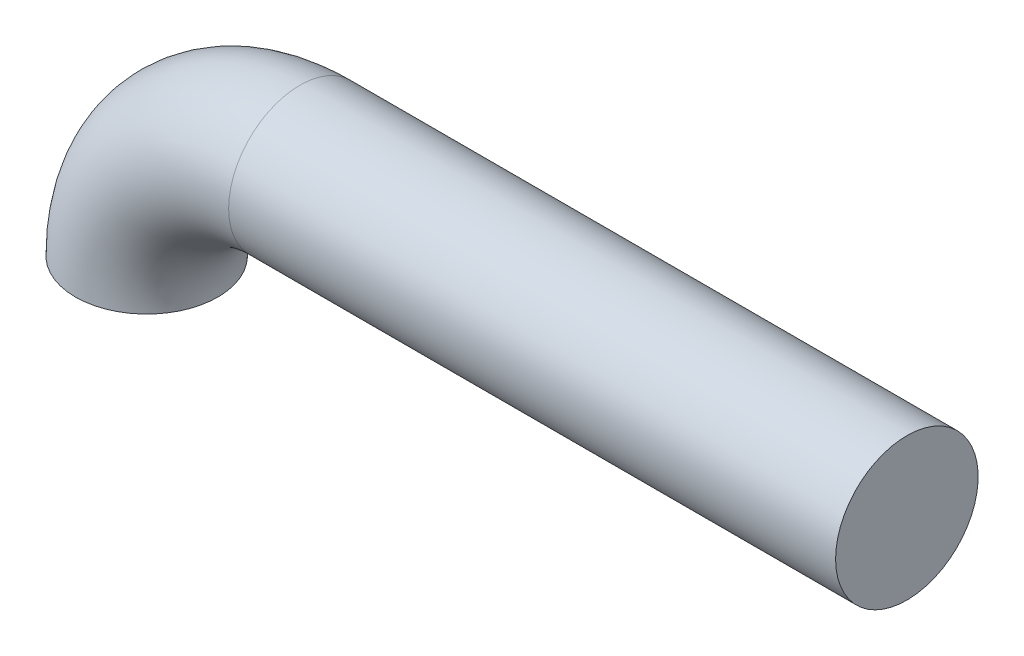
from build123d import *

# Parameters (mm, degrees)
SKETCH_1_R = 60


with BuildPart() as part:
    # По траектории1: sweep along a path in Эскиз2
    with BuildLine(Plane.XY) as sweep_1_path:
        Line((640, 129), (129, 129))
        ThreePointArc((129, 129), (37.783225227, 91.216774773), (0, 0))
    # Эскиз1 → По траектории1 (sweep)
    with BuildSketch(Plane(origin=(0, 0, 0), x_dir=(1, 0, 0), z_dir=(0, 1, 0))):
        Circle(SKETCH_1_R)
    sweep(path=sweep_1_path.line)


solid = part.part
